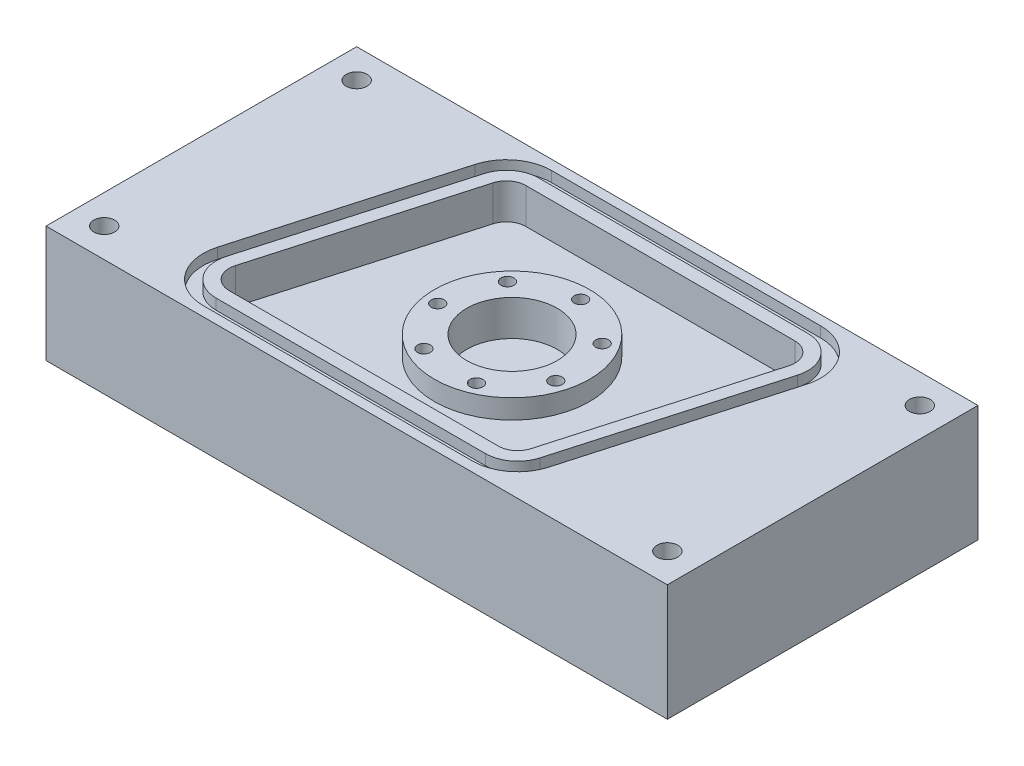
from build123d import *

# Parameters (mm, degrees)
SKETCH1_W                      = 152.4
SKETCH1_H                      = 76.2
BOSS_EXTRUDE1_DEPTH            = 28.575
F_7_0_201_DIAMETER_HOLE1_D     = 5.1054
F_7_0_201_DIAMETER_HOLE1_DEPTH = 12.7
F_7_0_201_DIAMETER_HOLE1_TIP   = 1.533816902
SKETCH4_R                      = 11.1125
CUT_EXTRUDE1_DEPTH             = 12.7
CIRPATTERN2_COUNT              = 7
SKETCH9_R                      = 19.05
CUT_EXTRUDE5_DEPTH             = 3.9624
SKETCH10_R                     = 19.05
CUT_EXTRUDE6_DEPTH             = 8.7122
CUT_EXTRUDE7_DEPTH             = 2.5908


with BuildPart() as part:
    # Sketch1 → Boss-Extrude1 (new body)
    with BuildSketch(Plane(origin=(0, 0, 0), x_dir=(1, 0, 0), z_dir=(0, 1, 0))):
        Rectangle(SKETCH1_W, SKETCH1_H)
    extrude(amount=BOSS_EXTRUDE1_DEPTH)

    # #7 (0.201) Diameter Hole1
    with Locations(Plane(origin=(0, 28.575, 0), x_dir=(-1, 0, 0), z_dir=(0, 1, 0))):
        with Locations((69.0626, -30.9626), (69.0626, 30.9626), (-69.0626, 30.9626), (-69.0626, -30.9626)):
            Hole(F_7_0_201_DIAMETER_HOLE1_D / 2, depth=F_7_0_201_DIAMETER_HOLE1_DEPTH)
            with Locations((0, 0, -(F_7_0_201_DIAMETER_HOLE1_DEPTH + F_7_0_201_DIAMETER_HOLE1_TIP / 2))):  # 118° drill point
                Cone(0, F_7_0_201_DIAMETER_HOLE1_D / 2, F_7_0_201_DIAMETER_HOLE1_TIP, mode=Mode.SUBTRACT)

    # Sketch4 → Cut-Extrude1 (cut)
    with BuildSketch(Plane(origin=(0, 28.575, 0), x_dir=(1, 0, 0), z_dir=(0, 1, 0))):
        Circle(SKETCH4_R)
    extrude(amount=-CUT_EXTRUDE1_DEPTH, mode=Mode.SUBTRACT)

    # Sketch14 → 1/8 (0.125) Diameter Hole2 (revolve, cut)
    with BuildSketch(Plane(origin=(13.004038703, 28.575, -9.105525927), x_dir=(0, 0, 1), z_dir=(1, 0, 0))):
        Polygon((0, 0), (0, 13.653866233), (1.5875, 12.7), (1.5875, 0), align=None)
    f_1_8_0_125_diameter_hole2 = revolve(axis=Axis((13.004038703, 34.925, -9.105525927), (0, -1, 0)), mode=Mode.SUBTRACT)

    # CirPattern2: 1/8 (0.125) Diameter Hole2 ×7 about axis
    cirpattern2_axis = Axis((0, 0, 0), (0, 1, 0))
    for i in range(1, CIRPATTERN2_COUNT):
        add(f_1_8_0_125_diameter_hole2.rotate(cirpattern2_axis, i * 360 / CIRPATTERN2_COUNT), mode=Mode.SUBTRACT)

    # Sketch9 → Cut-Extrude5 (cut)
    with BuildSketch(Plane(origin=(0, 28.575, 0), x_dir=(1, 0, 0), z_dir=(0, 1, 0))):
        Circle(SKETCH9_R)
    extrude(amount=-CUT_EXTRUDE5_DEPTH, mode=Mode.SUBTRACT)

    # Sketch10 → Cut-Extrude6 (cut)
    with BuildSketch(Plane(origin=(0, 28.575, 0), x_dir=(1, 0, 0), z_dir=(0, 1, 0))):
        with BuildLine():
            Line((-25.9842, 29.3624), (40.005, 29.3624))
            ThreePointArc((40.005, 29.3624), (43.806157259, 27.469152471), (44.585149022, 23.294663934))
            Line((44.585149022, 23.294663934), (30.564349022, -25.905136066))
            ThreePointArc((30.564349022, -25.905136066), (28.853452471, -28.401057259), (25.9842, -29.3624))
            Line((25.9842, -29.3624), (-40.005, -29.3624))
            ThreePointArc((-40.005, -29.3624), (-43.806157259, -27.469152471), (-44.585149022, -23.294663934))
            Line((-44.585149022, -23.294663934), (-30.564349022, 25.905136066))
            ThreePointArc((-30.564349022, 25.905136066), (-28.853452471, 28.401057259), (-25.9842, 29.3624))
        make_face()
        Circle(SKETCH10_R, mode=Mode.SUBTRACT)
    extrude(amount=-CUT_EXTRUDE6_DEPTH, mode=Mode.SUBTRACT)

    # Sketch11 → Cut-Extrude7 (cut)
    with BuildSketch(Plane(origin=(0, 28.575, 0), x_dir=(1, 0, 0), z_dir=(0, 1, 0))):
        with BuildLine():
            Line((-36.671214384, 27.645450821), (-50.692014384, -21.554349179))
            ThreePointArc((-50.692014384, -21.554349179), (-48.874366938, -31.294822432), (-40.005, -35.7124))
            Line((-40.005, -35.7124), (25.9842, -35.7124))
            ThreePointArc((25.9842, -35.7124), (32.679122432, -33.469266938), (36.671214384, -27.645450821))
            Line((36.671214384, -27.645450821), (50.692014384, 21.554349179))
            ThreePointArc((50.692014384, 21.554349179), (48.874366938, 31.294822432), (40.005, 35.7124))
            Line((40.005, 35.7124), (-25.9842, 35.7124))
            ThreePointArc((-25.9842, 35.7124), (-32.679122432, 33.469266938), (-36.671214384, 27.645450821))
        make_face()
        with BuildLine():
            Line((-33.617781703, 26.775293443), (-47.638581703, -22.424506557))
            ThreePointArc((-47.638581703, -22.424506557), (-46.340262098, -29.381987452), (-40.005, -32.5374))
            Line((-40.005, -32.5374), (25.9842, -32.5374))
            ThreePointArc((25.9842, -32.5374), (30.766287452, -30.935162098), (33.617781703, -26.775293443))
            Line((33.617781703, -26.775293443), (47.638581703, 22.424506557))
            ThreePointArc((47.638581703, 22.424506557), (46.340262098, 29.381987452), (40.005, 32.5374))
            Line((40.005, 32.5374), (-25.9842, 32.5374))
            ThreePointArc((-25.9842, 32.5374), (-30.766287452, 30.935162098), (-33.617781703, 26.775293443))
        make_face(mode=Mode.SUBTRACT)
    extrude(amount=-CUT_EXTRUDE7_DEPTH, mode=Mode.SUBTRACT)


solid = part.part
